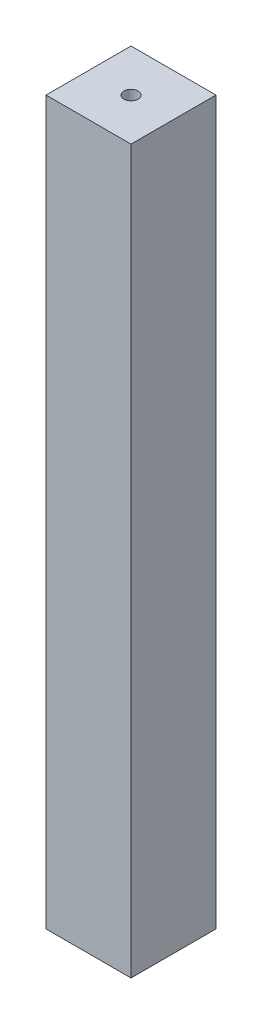
from build123d import *

# Parameters (mm, degrees)
SKETCH1_W           = 30
SKETCH1_H           = 30
SKETCH1_W_2         = 20
SKETCH1_H_2         = 20
BOSS_EXTRUDE1_DEPTH = 250
SKETCH2_W           = 30
SKETCH2_H           = 30
SKETCH2_R           = 2.5
BOSS_EXTRUDE2_DEPTH = 5


with BuildPart() as part:
    # Sketch1 → Boss-Extrude1 (new body)
    with BuildSketch(Plane(origin=(0, 0, 0), x_dir=(1, 0, 0), z_dir=(0, 1, 0))):
        with Locations((15, 15)):
            Rectangle(SKETCH1_W, SKETCH1_H)
        with Locations((15, 15)):
            Rectangle(SKETCH1_W_2, SKETCH1_H_2, mode=Mode.SUBTRACT)
    extrude(amount=BOSS_EXTRUDE1_DEPTH)

    # Sketch2 → Boss-Extrude2 (add)
    with BuildSketch(Plane(origin=(0, 250, 0), x_dir=(1, 0, 0), z_dir=(0, 1, 0))):
        with Locations((15, 15)):
            Rectangle(SKETCH2_W, SKETCH2_H)
        with Locations((15, 15)):
            Circle(SKETCH2_R, mode=Mode.SUBTRACT)
    extrude(amount=BOSS_EXTRUDE2_DEPTH)


solid = part.part
